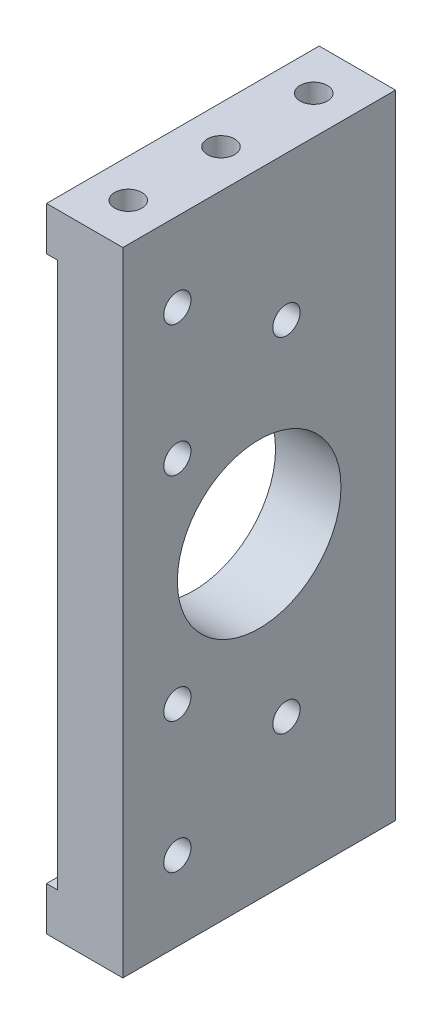
from build123d import *

# Parameters (mm, degrees)
EXTRUDE_1_DEPTH             = 25
SKETCH_2_W                  = 1
SKETCH_2_H                  = 50
CUT_EXTRUDE_1_DEPTH         = 26
SKETCH_3_W                  = 52
SKETCH_3_H                  = 1
EXTRUDE_2_DEPTH             = 25
SKETCH_4_W                  = 2
SKETCH_4_H                  = 1
EXTRUDE_3_DEPTH             = 25
SKETCH_5_W                  = 2
SKETCH_5_H                  = 1
EXTRUDE_4_DEPTH             = 25
SKETCH_6_W                  = 11
SKETCH_6_H                  = 1
CUT_EXTRUDE_2_DEPTH         = 26
SKETCH_7_R                  = 8.5
CUT_EXTRUDE_3_DEPTH         = 64
SKETCH_8_R                  = 9.5
CUT_EXTRUDE_4_DEPTH         = 5
SKETCH_9_W                  = 2
SKETCH_9_H                  = 5
EXTRUDE_5_DEPTH             = 25
HOLE_WIZARD_1_D             = 3.4
HOLE_WIZARD_1_DEPTH         = 5
HOLE_WIZARD_1_CBORE_D       = 6
HOLE_WIZARD_1_CBORE_DEPTH   = 3
SKETCH_14_R                 = 1.5
CUT_EXTRUDE_8_DEPTH         = 5
SKETCH_22_W                 = 25
SKETCH_22_H                 = 52
EXTRUDE_9_DEPTH             = 2
CUT_EXTRUDE_START           = -6
CUT_EXTRUDE_10_DEPTH        = 6
CUT_EXTRUDE_11_REACH        = 173
SKETCH_17_R                 = 7.5
CUT_EXTRUDE_12_DEPTH        = 60
HOLE_WIZARD_M3_1_D          = 2.5
HOLE_WIZARD_M3_1_DEPTH      = 8.5
HOLE_WIZARD_M3_1_TIP        = 0.751075774
HOLE_WIZARD_M3_2_AT_2_COUNT = 2
HOLE_WIZARD_M3_2_AT_2_PITCH = 8.5
HOLE_WIZARD_M3_2_AT_3_COUNT = 2
HOLE_WIZARD_M3_2_AT_3_PITCH = 17


with BuildPart() as part:
    # 草图1 → 凸台-拉伸1 (new body)
    with BuildSketch(Plane.XY):
        Polygon((-81, -29), (86, -29), (86, -34), (-86, -34), (-86, -29), (-86, 29), (-81, 29), align=None)
    extrude(amount=EXTRUDE_1_DEPTH)

    # 草图2 → 切除-拉伸1 (cut, through all)
    with BuildSketch(Plane.XY.offset(25)):
        with Locations((-85.5, 0)):
            Rectangle(SKETCH_2_W, SKETCH_2_H)
    extrude(amount=-CUT_EXTRUDE_1_DEPTH, mode=Mode.SUBTRACT)

    # 草图3 → 凸台-拉伸2 (add)
    with BuildSketch(Plane.XY.offset(25)):
        with Locations((0, -28.5)):
            Rectangle(SKETCH_3_W, SKETCH_3_H)
    extrude(amount=-EXTRUDE_2_DEPTH)

    # 草图4 → 凸台-拉伸3 (add)
    with BuildSketch(Plane.XY.offset(25)):
        with Locations((-80, -28.5)):
            Rectangle(SKETCH_4_W, SKETCH_4_H)
    extrude(amount=-EXTRUDE_3_DEPTH)

    # 草图5 → 凸台-拉伸4 (add)
    with BuildSketch(Plane.XY.offset(25)):
        with Locations((78, -28.5)):
            Rectangle(SKETCH_5_W, SKETCH_5_H)
    extrude(amount=-EXTRUDE_4_DEPTH)

    # 草图6 → 切除-拉伸2 (cut, through all)
    with BuildSketch(Plane.XY.offset(25)):
        with Locations((-20.5, -33.5)):
            Rectangle(SKETCH_6_W, SKETCH_6_H)
    cut_extrude_2 = extrude(amount=-CUT_EXTRUDE_2_DEPTH, mode=Mode.SUBTRACT)

    # 镜向1: 切除-拉伸2 across plane
    add(cut_extrude_2.mirror(Plane(origin=(0, 0, 0), x_dir=(0, 0, 1), z_dir=(1, 0, 0))), mode=Mode.SUBTRACT)

    # 草图7 → 切除-拉伸3 (cut, through all)
    with BuildSketch(Plane.XZ.offset(34)):
        with Locations((0, 12.5)):
            Circle(SKETCH_7_R)
    extrude(amount=-CUT_EXTRUDE_3_DEPTH, mode=Mode.SUBTRACT)

    # 草图8 → 切除-拉伸4 (cut)
    with BuildSketch(Plane(origin=(0, -28, 0), x_dir=(1, 0, 0), z_dir=(0, 1, 0))):
        with Locations((0, -12.5)):
            Circle(SKETCH_8_R)
    extrude(amount=-CUT_EXTRUDE_4_DEPTH, mode=Mode.SUBTRACT)

    # 草图9 → 凸台-拉伸5 (add)
    with BuildSketch(Plane(origin=(0, 0, 0), x_dir=(-1, 0, 0), z_dir=(0, 0, -1))):
        with Locations((80, 26.5)):
            Rectangle(SKETCH_9_W, SKETCH_9_H)
    extrude(amount=-EXTRUDE_5_DEPTH)

    # 孔1
    with Locations(Plane(origin=(82.5, -34, 21), x_dir=(-1, 0, 0), z_dir=(0, -1, 0))):
        with Locations((0, 0), (0, 8.5), (0, 17)):
            CounterBoreHole(HOLE_WIZARD_1_D / 2, HOLE_WIZARD_1_CBORE_D / 2, HOLE_WIZARD_1_CBORE_DEPTH, depth=HOLE_WIZARD_1_DEPTH)

    # 草图14 → 切除-拉伸8 (cut)
    with BuildSketch(Plane.XZ.offset(33)):
        with Locations((-23, 20)):
            Circle(SKETCH_14_R)
        with Locations((-23, 5)):
            Circle(SKETCH_14_R)
    cut_extrude_8 = extrude(amount=-CUT_EXTRUDE_8_DEPTH, mode=Mode.SUBTRACT)

    # 镜向2: 切除-拉伸8 across plane
    add(cut_extrude_8.mirror(Plane(origin=(0, 0, 0), x_dir=(0, 0, 1), z_dir=(1, 0, 0))), mode=Mode.SUBTRACT)

    # 草图22 → 凸台-拉伸9 (add)
    with BuildSketch(Plane(origin=(-81, 0, 0), x_dir=(0, 0, -1), z_dir=(1, 0, 0))):
        with Locations((-12.5, -2)):
            Rectangle(SKETCH_22_W, SKETCH_22_H)
    extrude(amount=EXTRUDE_9_DEPTH)

    # 草图16 → 切除-拉伸10 (cut)
    with BuildSketch(Plane.XZ.offset(34).offset(CUT_EXTRUDE_START)):
        with BuildLine():
            Line((-73, 20), (-30, 20))
            ThreePointArc((-30, 20), (-26.464466094, 18.535533906), (-25, 15))
            Line((-25, 15), (-25, 10))
            ThreePointArc((-25, 10), (-26.464466094, 6.464466094), (-30, 5))
            Line((-30, 5), (-73, 5))
            ThreePointArc((-73, 5), (-76.535533906, 6.464466094), (-78, 10))
            Line((-78, 10), (-78, 15))
            ThreePointArc((-78, 15), (-76.535533906, 18.535533906), (-73, 20))
        make_face()
    cut_extrude_10 = extrude(amount=CUT_EXTRUDE_10_DEPTH, mode=Mode.SUBTRACT)

    # 镜向3: 切除-拉伸10 across plane
    add(cut_extrude_10.mirror(Plane(origin=(0, 0, 0), x_dir=(0, 0, 1), z_dir=(1, 0, 0))), mode=Mode.SUBTRACT)

    # 草图17 → 切除-拉伸11 (cut, up to next)
    with BuildSketch(Plane.ZY.offset(85), mode=Mode.PRIVATE) as cut_extrude_11_sk1:
        with Locations((12.5, 0)):
            Circle(SKETCH_17_R)
    cut_extrude_11_tool1 = extrude(cut_extrude_11_sk1.sketch, amount=-CUT_EXTRUDE_11_REACH, mode=Mode.PRIVATE) & part.part
    add(cut_extrude_11_tool1.solids().sort_by_distance((-85, 0, 12.5))[0], mode=Mode.SUBTRACT)

    # 草图18 → 切除-拉伸12 (cut)
    with BuildSketch(Plane.XY.offset(25)):
        Polygon((-79, -29), (-86, -29), (-86, -34), (86, -34), (86, -25.759087468), (-79, -25.759087468), align=None)
    extrude(amount=-CUT_EXTRUDE_12_DEPTH, mode=Mode.SUBTRACT)

    # M3 螺纹孔1
    with Locations(Plane(origin=(-85, 21.75, 20), x_dir=(0, 0, -1), z_dir=(-1, 0, 0))):
        with Locations((0, 0), (0, 12), (10, 6), (0, 31.5), (0, 43.5), (10, 37.5)):
            Hole(HOLE_WIZARD_M3_1_D / 2, depth=HOLE_WIZARD_M3_1_DEPTH)
            with Locations((0, 0, -(HOLE_WIZARD_M3_1_DEPTH + HOLE_WIZARD_M3_1_TIP / 2))):  # 118° drill point
                Cone(0, HOLE_WIZARD_M3_1_D / 2, HOLE_WIZARD_M3_1_TIP, mode=Mode.SUBTRACT)

    # 草图24 → M3 螺纹孔2 (revolve, cut)
    with BuildSketch(Plane(origin=(-82.5, 29, 21), x_dir=(0, 0, 1), z_dir=(1, 0, 0))):
        Polygon((0, 0), (0, 5.751075774), (1.25, 5), (1.25, 0), align=None)
    hole_wizard_m3_2 = revolve(axis=Axis((-82.5, 35.35, 21), (0, -1, 0)), mode=Mode.SUBTRACT)

    # M3 螺纹孔2 at 2: M3 螺纹孔2 ×2
    with Locations(*[(0, 0, -i * HOLE_WIZARD_M3_2_AT_2_PITCH) for i in range(1, HOLE_WIZARD_M3_2_AT_2_COUNT)]):
        add(hole_wizard_m3_2, mode=Mode.SUBTRACT)

    # M3 螺纹孔2 at 3: M3 螺纹孔2 ×2
    with Locations(*[(0, 0, -i * HOLE_WIZARD_M3_2_AT_3_PITCH) for i in range(1, HOLE_WIZARD_M3_2_AT_3_COUNT)]):
        add(hole_wizard_m3_2, mode=Mode.SUBTRACT)

    # 镜向4: M3 螺纹孔2 across plane
    add(hole_wizard_m3_2.mirror(Plane.ZX), mode=Mode.SUBTRACT)

    # 镜向4 copy 1 sketch → 镜向4 copy 1 (revolve, cut)
    with BuildSketch(Plane(origin=(-82.5, -29, 12.5), x_dir=(0, 0, 1), z_dir=(1, 0, 0))):
        Polygon((0, 0), (0, -5.751075774), (1.25, -5), (1.25, 0), align=None)
    revolve(axis=Axis((-82.5, -35.35, 12.5), (0, -1, 0)), mode=Mode.SUBTRACT)

    # 镜向4 copy 2 sketch → 镜向4 copy 2 (revolve, cut)
    with BuildSketch(Plane(origin=(-82.5, -29, 4), x_dir=(0, 0, 1), z_dir=(1, 0, 0))):
        Polygon((0, 0), (0, -5.751075774), (1.25, -5), (1.25, 0), align=None)
    revolve(axis=Axis((-82.5, -35.35, 4), (0, -1, 0)), mode=Mode.SUBTRACT)


solid = part.part
